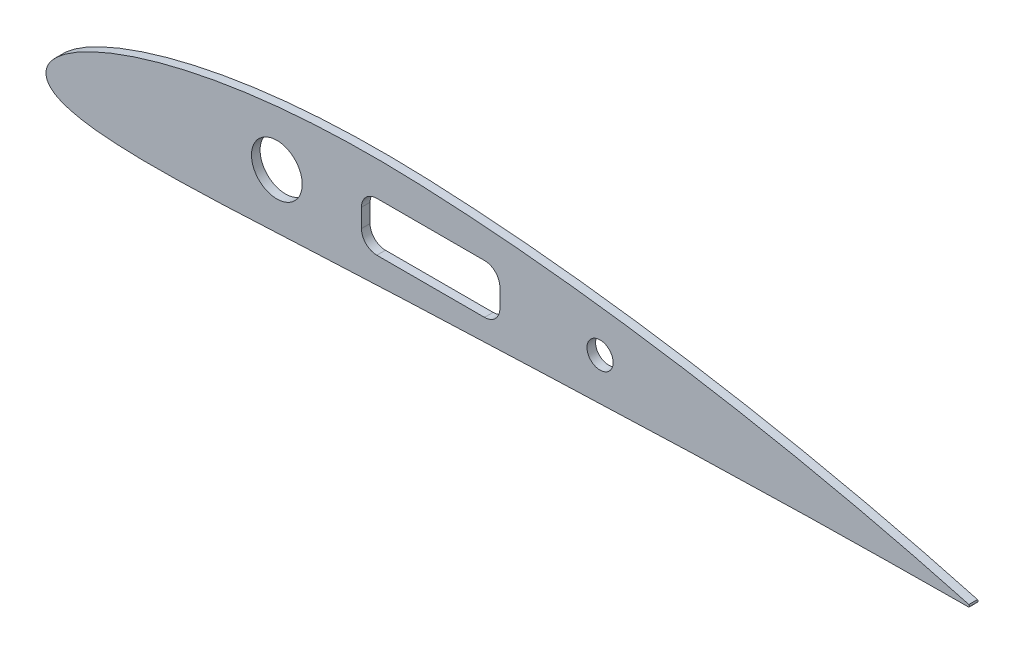
from build123d import *

# Parameters (mm, degrees)
SKETCH_1_R      = 8.25
SKETCH_1_R_2    = 4.25
EXTRUDE_1_DEPTH = 1.4


with BuildPart() as part:
    # Эскиз1 → Бобышка-Вытянуть1 (new body, symmetric)
    with BuildSketch(Plane.XY):
        with BuildLine():
            Line((0.05757, 0.74571), (0, 0))
            Line((0, 0), (0.00249, -0.14724))
            add(Edge.make_bspline(
                [(0.00249, -0.14724), (0.028864169, -0.445513844), (0.08330578, -1.0612113), (0.42267139, -1.966638227), (0.976281815, -2.838072896), (1.756459788, -3.647133325), (2.749077941, -4.393198402), (3.967143746, -5.082935859), (5.442296909, -5.728408867), (7.235698246, -6.338630634), (9.442776227, -6.918379999), (12.202598128, -7.466059916), (15.690525654, -7.967542476), (20.073738499, -8.391548086), (25.427942493, -8.696814173), (31.679981306, -8.851966619), (38.636878275, -8.851508296), (46.077368111, -8.713723896), (53.829146121, -8.46796963), (61.783851715, -8.143744238), (69.877177119, -7.766789504), (78.062513527, -7.359422717), (86.292927251, -6.940806212), (94.525650691, -6.527616544), (102.732598332, -6.133141503), (110.918529108, -5.765943991), (119.106037428, -5.438377986), (127.316854086, -5.133929605), (135.563054016, -4.803707911), (143.837285105, -4.467811421), (152.128632568, -4.128080756), (160.417875856, -3.790434721), (168.698244489, -3.458856865), (176.966416514, -3.13670755), (185.223122893, -2.826751698), (193.470052961, -2.531243905), (201.709043695, -2.251960889), (209.941894226, -1.990371725), (218.170315159, -1.747653748), (226.395881355, -1.524460053), (234.619974201, -1.321335461), (242.843439472, -1.138340626), (253.799028348, -0.921290824), (264.723718399, -0.743927691), (275.541156207, -0.603511416), (283.304824625, -0.51781703), (290.376932295, -0.451824554), (295.870764013, -0.407443063), (298.944589157, -0.385525491), (300, -0.378)],
                knots=[0, 0, 0, 0, 0.002951555, 0.006092605, 0.0094509, 0.013105035, 0.017145832, 0.021696099, 0.026921577, 0.033052787, 0.04041788, 0.049480062, 0.060872195, 0.075263112, 0.093030359, 0.113913711, 0.137122623, 0.161846788, 0.187529051, 0.213844768, 0.24060404, 0.267679501, 0.294919064, 0.322129352, 0.349224887, 0.376200636, 0.403190533, 0.430285051, 0.457482609, 0.484832061, 0.51220601, 0.539574277, 0.566902094, 0.594185889, 0.621429901, 0.648639753, 0.675821648, 0.702981565, 0.730124952, 0.757257324, 0.784383539, 0.811507209, 0.838628701, 0.892783781, 0.919594556, 0.94565005, 0.969591155, 0.989558995, 1, 1, 1, 1], degree=3))
            ThreePointArc((300, -0.378), (300.156572727, 0), (300, 0.378))
            add(Edge.make_bspline(
                [(300, 0.378), (298.986801288, 0.654023781), (296.064210837, 1.450219491), (290.8695985, 2.830006863), (284.219713445, 4.545150437), (276.935901935, 6.357610605), (269.347101537, 8.175439233), (261.636652195, 9.949932759), (253.874886054, 11.663682068), (246.086893811, 13.310849919), (238.281565095, 14.889420872), (230.462843896, 16.398357509), (222.633143967, 17.836911964), (214.794406789, 19.204085734), (206.94847769, 20.498865738), (199.097180514, 21.719793409), (191.242416875, 22.865402178), (183.386166154, 23.933862723), (175.530527282, 24.923138619), (167.67763175, 25.830811336), (159.830204076, 26.654405099), (151.990419631, 27.390865714), (144.164125102, 28.036767919), (136.354280569, 28.589612789), (128.583278445, 29.040291112), (120.889314832, 29.398079412), (113.294103258, 29.623979722), (105.787101592, 29.68811478), (98.338851666, 29.590618972), (90.93662471, 29.32921657), (83.58443153, 28.898261785), (76.290492602, 28.293607633), (69.066227461, 27.50993599), (61.926915226, 26.542878626), (54.893280374, 25.387877318), (47.995029113, 24.042445667), (41.277503811, 22.507579481), (34.812458524, 20.793138729), (28.71095809, 18.926237906), (23.124814608, 16.961123321), (18.21491807, 14.980002525), (14.088570948, 13.074733194), (10.751246243, 11.315492838), (8.113069416, 9.730323839), (6.040451698, 8.309565666), (4.40603392, 7.025075597), (3.110521348, 5.845566442), (2.085810802, 4.743114892), (1.283844996, 3.697135648), (0.685974492, 2.689946523), (0.258928679, 1.716942476), (0.122706698, 1.059890033), (0.05757, 0.74571)],
                knots=[0, 0, 0, 0, 0.0101622, 0.029313053, 0.052011605, 0.076619468, 0.101948061, 0.127526132, 0.153184131, 0.178867888, 0.204557903, 0.230245712, 0.255925967, 0.281594302, 0.30724642, 0.332878042, 0.358484538, 0.384061186, 0.409602822, 0.435103874, 0.460559416, 0.485959195, 0.51130307, 0.536551515, 0.561723366, 0.586628867, 0.611085431, 0.6352512, 0.659272176, 0.683163753, 0.706922144, 0.73053591, 0.7539832, 0.77723469, 0.800246382, 0.822950709, 0.845237155, 0.866915896, 0.887662335, 0.906968281, 0.924203157, 0.938878975, 0.950931611, 0.960693484, 0.968646729, 0.975232933, 0.980794744, 0.985583761, 0.989781539, 0.993521313, 0.996902113, 1, 1, 1, 1], degree=3))
        make_face()
        with Locations((75.041010682, 10.315576588)):
            Circle(SKETCH_1_R, mode=Mode.SUBTRACT)
        with Locations((180.094939636, 10.662445034)):
            Circle(SKETCH_1_R_2, mode=Mode.SUBTRACT)
        with BuildLine():
            Line((107.541010682, 2.480667246), (142.541010682, 2.480667246))
            ThreePointArc((142.541010682, 2.480667246), (146.076544588, 3.94513334), (147.541010682, 7.480667246))
            Line((147.541010682, 7.480667246), (147.541010682, 13.480667246))
            ThreePointArc((147.541010682, 13.480667246), (146.076544588, 17.016201152), (142.541010682, 18.480667246))
            Line((142.541010682, 18.480667246), (107.541010682, 18.480667246))
            ThreePointArc((107.541010682, 18.480667246), (104.005476776, 17.016201152), (102.541010682, 13.480667246))
            Line((102.541010682, 13.480667246), (102.541010682, 7.480667246))
            ThreePointArc((102.541010682, 7.480667246), (104.005476776, 3.94513334), (107.541010682, 2.480667246))
        make_face(mode=Mode.SUBTRACT)
    extrude(amount=EXTRUDE_1_DEPTH, both=True)


solid = part.part
